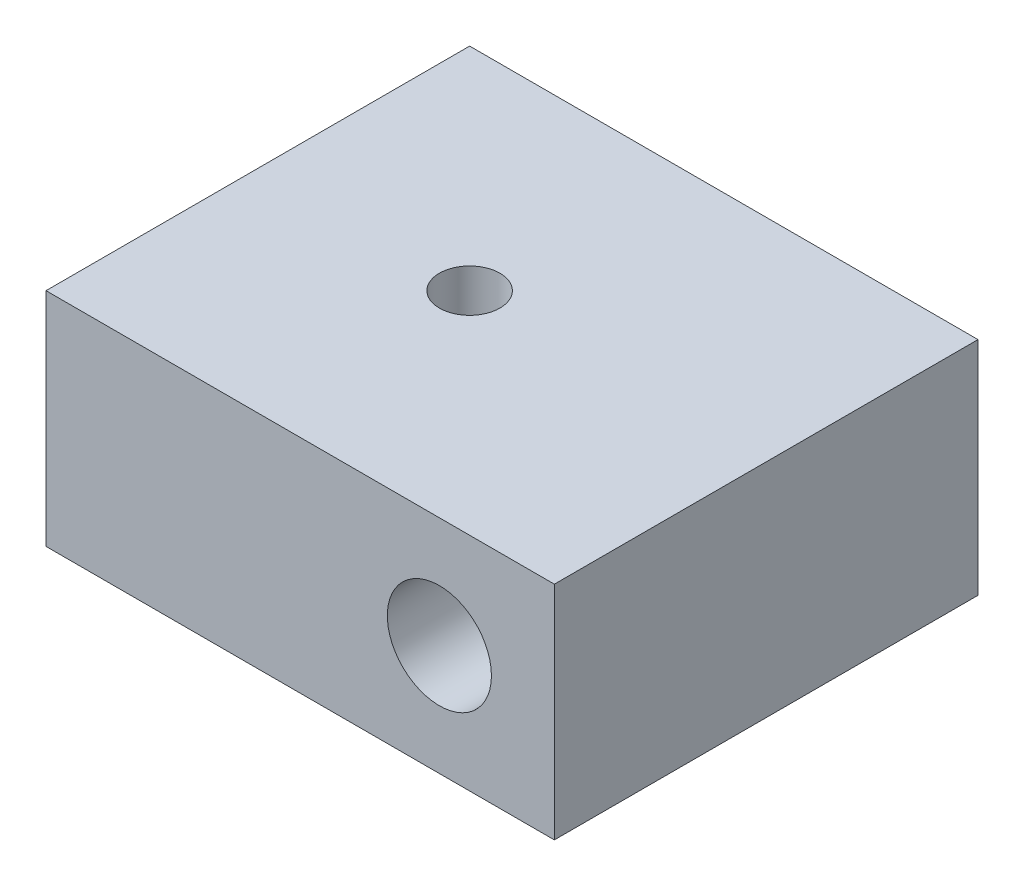
from build123d import *

# Parameters (mm, degrees)
SKETCH1_W           = 42
SKETCH1_H           = 35
SKETCH1_R           = 2.5
BOSS_EXTRUDE1_DEPTH = 18.3
SKETCH2_R           = 4.3
CUT_EXTRUDE1_DEPTH  = 36


with BuildPart() as part:
    # Sketch1 → Boss-Extrude1 (new body)
    with BuildSketch(Plane(origin=(0, 0, 0), x_dir=(1, 0, 0), z_dir=(0, 1, 0))):
        with Locations((21, 17.5)):
            Rectangle(SKETCH1_W, SKETCH1_H)
        with Locations((17.5, 17.5)):
            Circle(SKETCH1_R, mode=Mode.SUBTRACT)
    extrude(amount=BOSS_EXTRUDE1_DEPTH)

    # Sketch2 → Cut-Extrude1 (cut, through all)
    with BuildSketch(Plane.XY):
        with Locations((32.5, 9.15)):
            Circle(SKETCH2_R)
    extrude(amount=-CUT_EXTRUDE1_DEPTH, mode=Mode.SUBTRACT)


solid = part.part
